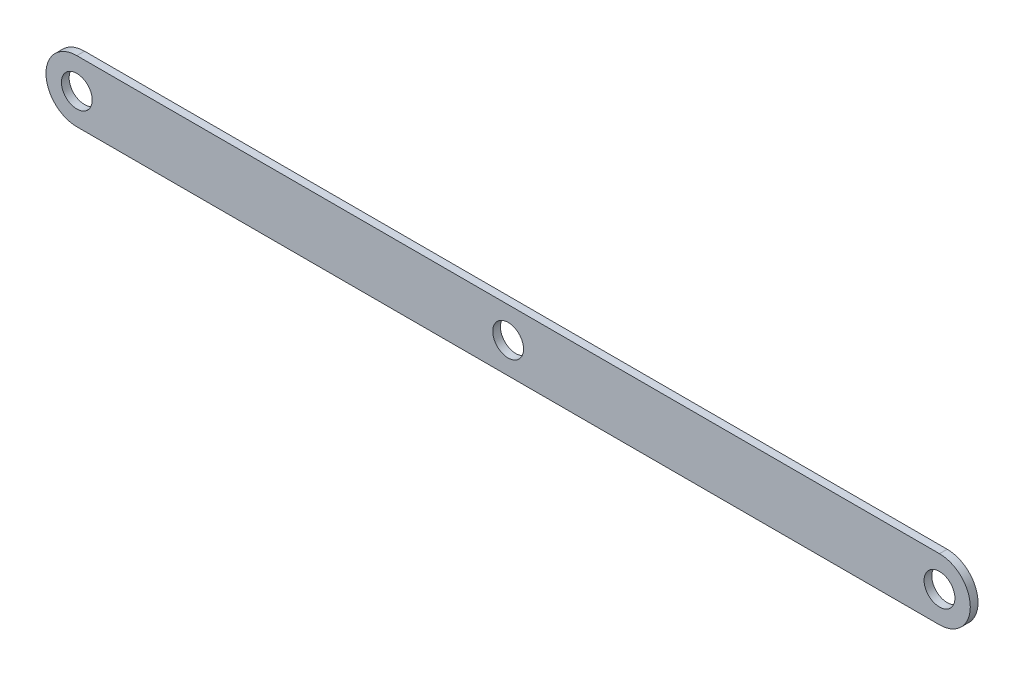
from build123d import *

# Parameters (mm, degrees)
SKETCH1_R           = 6.35
BOSS_EXTRUDE1_DEPTH = 3.175


with BuildPart() as part:
    # Sketch1 → Boss-Extrude1 (new body)
    with BuildSketch(Plane.XY):
        with BuildLine():
            Line((177.8, -12.7), (-177.8, -12.7))
            ThreePointArc((-177.8, -12.7), (-190.5, 0), (-177.8, 12.7))
            Line((-177.8, 12.7), (177.8, 12.7))
            ThreePointArc((177.8, 12.7), (190.5, 0), (177.8, -12.7))
        make_face()
        with Locations((-177.8, 0)):
            Circle(SKETCH1_R, mode=Mode.SUBTRACT)
        Circle(SKETCH1_R, mode=Mode.SUBTRACT)
        with Locations((177.8, 0)):
            Circle(SKETCH1_R, mode=Mode.SUBTRACT)
    extrude(amount=BOSS_EXTRUDE1_DEPTH)


solid = part.part
